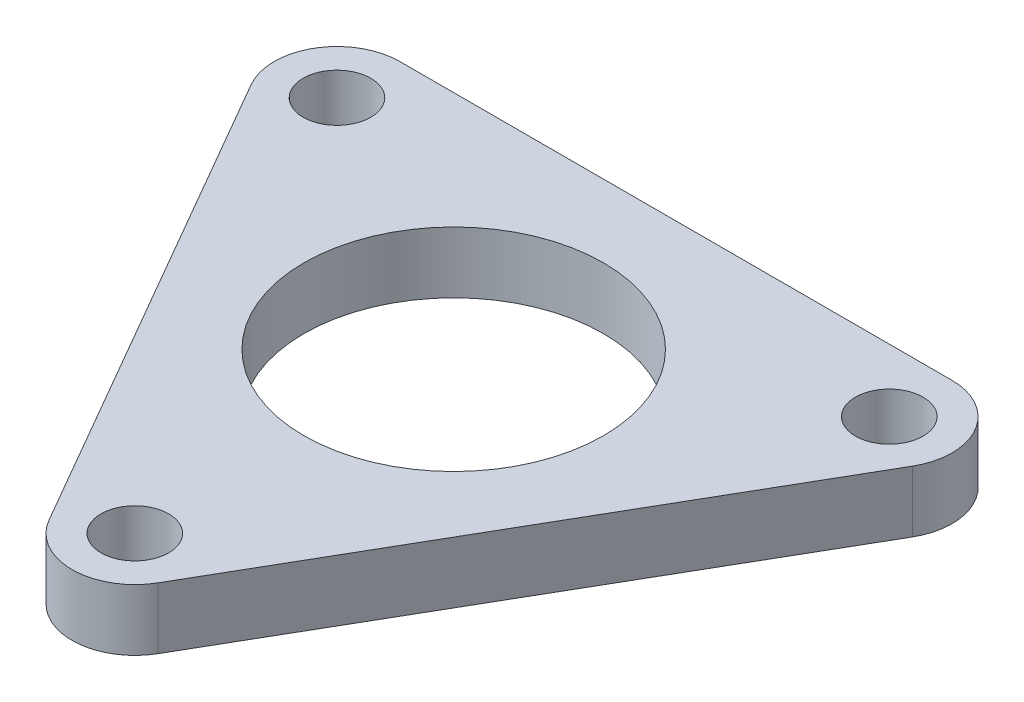
from build123d import *

# Parameters (mm, degrees)
SKETCH1_R           = 7.75
SKETCH1_R_2         = 1.75
BOSS_EXTRUDE1_DEPTH = 3.175


with BuildPart() as part:
    # Sketch1 → Boss-Extrude1 (new body)
    with BuildSketch(Plane(origin=(0, 0, 0), x_dir=(1, 0, 0), z_dir=(0, 1, 0))):
        with BuildLine():
            Line((-17.104001725, 6.625), (-2.814582562, -18.125))
            ThreePointArc((-2.814582562, -18.125), (0, -19.75), (2.814582562, -18.125))
            Line((2.814582562, -18.125), (17.104001725, 6.625))
            ThreePointArc((17.104001725, 6.625), (17.104001725, 9.875), (14.289419162, 11.5))
            Line((14.289419162, 11.5), (-14.289419162, 11.5))
            ThreePointArc((-14.289419162, 11.5), (-17.104001725, 9.875), (-17.104001725, 6.625))
        make_face()
        with Locations(Location((0, 0, 0), (0, 0, 270))):  # turned: the seam where the file's is
            Circle(SKETCH1_R, mode=Mode.SUBTRACT)
        with Locations(Location((-14.289419162, 8.25, 0), (0, 0, 270))):  # turned: the seam where the file's is
            Circle(SKETCH1_R_2, mode=Mode.SUBTRACT)
        with Locations(Location((0, -16.5, 0), (0, 0, 270))):  # turned: the seam where the file's is
            Circle(SKETCH1_R_2, mode=Mode.SUBTRACT)
        with Locations(Location((14.289419162, 8.25, 0), (0, 0, 270))):  # turned: the seam where the file's is
            Circle(SKETCH1_R_2, mode=Mode.SUBTRACT)
    extrude(amount=BOSS_EXTRUDE1_DEPTH)


solid = part.part
